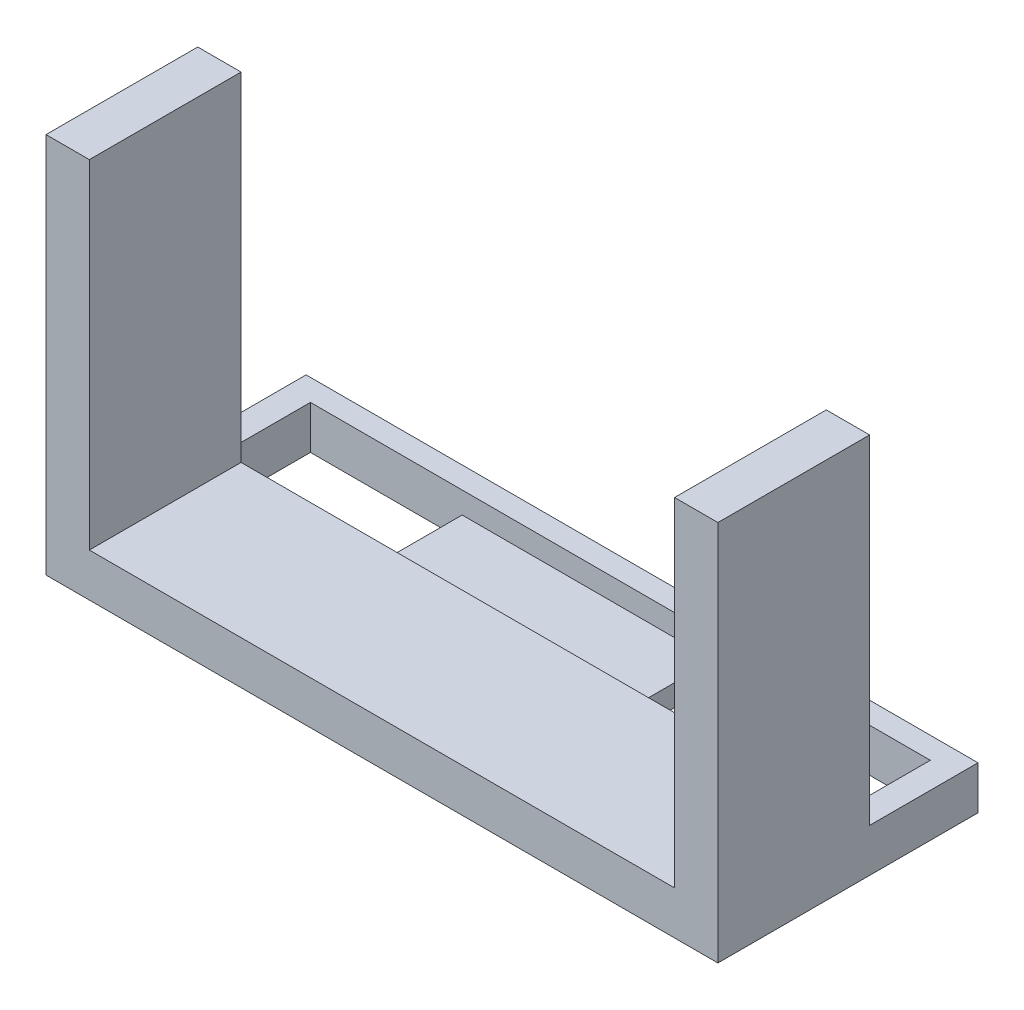
from build123d import *

# Parameters (mm, degrees)
SKETCH1_W           = 155
SKETCH1_H           = 60
BOSS_EXTRUDE1_DEPTH = 10
SKETCH2_W           = 143
SKETCH2_H           = 20
CUT_EXTRUDE1_DEPTH  = 5
SKETCH3_W           = 10
SKETCH3_H           = 35
BOSS_EXTRUDE2_DEPTH = 78
SKETCH4_W           = 35
SKETCH4_H           = 20
SKETCH4_W_2         = 50
CUT_EXTRUDE2_DEPTH  = 78


with BuildPart() as part:
    # Sketch1 → Boss-Extrude1 (new body)
    with BuildSketch(Plane(origin=(0, 0, 0), x_dir=(1, 0, 0), z_dir=(0, 1, 0))):
        with Locations((77.5, -30)):
            Rectangle(SKETCH1_W, SKETCH1_H)
    extrude(amount=BOSS_EXTRUDE1_DEPTH)

    # Sketch2 → Cut-Extrude1 (cut)
    with BuildSketch(Plane(origin=(0, 10, 0), x_dir=(1, 0, 0), z_dir=(0, 1, 0))):
        with Locations((77.5, -15)):
            Rectangle(SKETCH2_W, SKETCH2_H)
    extrude(amount=-CUT_EXTRUDE1_DEPTH, mode=Mode.SUBTRACT)

    # Sketch3 → Boss-Extrude2 (add)
    with BuildSketch(Plane(origin=(0, 10, 0), x_dir=(1, 0, 0), z_dir=(0, 1, 0))):
        with Locations((5, -42.5)):
            Rectangle(SKETCH3_W, SKETCH3_H)
        with Locations((150, -42.5)):
            Rectangle(SKETCH3_W, SKETCH3_H)
    extrude(amount=BOSS_EXTRUDE2_DEPTH)

    # Sketch4 → Cut-Extrude2 (cut)
    with BuildSketch(Plane(origin=(0, 5, 0), x_dir=(1, 0, 0), z_dir=(0, 1, 0))):
        with Locations((23.5, -15)):
            Rectangle(SKETCH4_W, SKETCH4_H)
        with Locations((124, -15)):
            Rectangle(SKETCH4_W_2, SKETCH4_H)
    extrude(amount=-CUT_EXTRUDE2_DEPTH, mode=Mode.SUBTRACT)


solid = part.part
